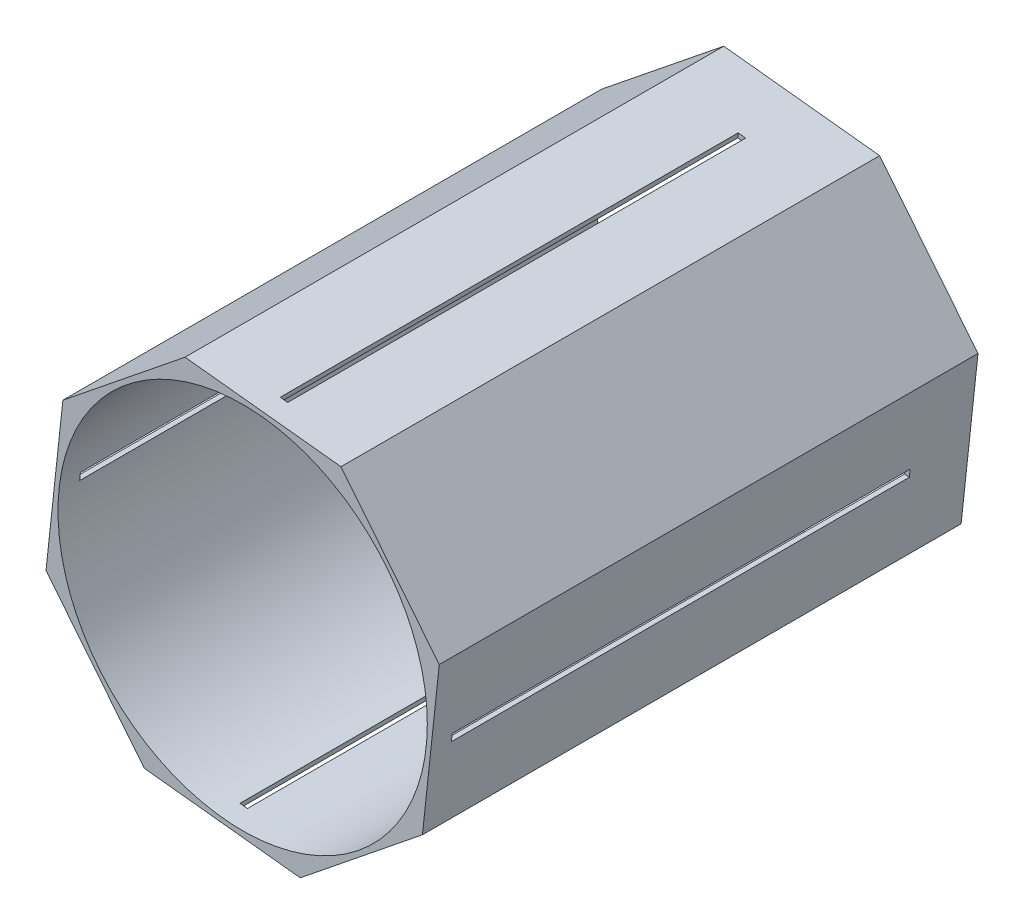
from build123d import *

# Parameters (mm, degrees)
SKETCH1_R           = 78.359
BOSS_EXTRUDE1_DEPTH = 228.6
SKETCH2_W           = 3.175
SKETCH2_H           = 194.31
CUT_EXTRUDE1_DEPTH  = 203.2
SKETCH5_W           = 194.31
SKETCH5_H           = 3.175
CUT_EXTRUDE2_DEPTH  = 203.2


with BuildPart() as part:
    # Sketch1 → Boss-Extrude1 (new body)
    with BuildSketch(Plane.XY):
        Polygon((76.286003624, -41.721564111), (83.443951376, 24.440749568), (41.721564111, 76.286003624), (-24.440749568, 83.443951376), (-76.286003624, 41.721564111), (-83.443951376, -24.440749568), (-41.721564111, -76.286003624), (24.440749568, -83.443951376), align=None)
        Circle(SKETCH1_R, mode=Mode.SUBTRACT)
    extrude(amount=BOSS_EXTRUDE1_DEPTH)

    # Sketch2 → Cut-Extrude1 (cut)
    with BuildSketch(Plane(origin=(8.640407271, 79.8649775, 0), x_dir=(0.99419859, -0.107560047, 0), z_dir=(0.107560047, 0.99419859, 0))):
        with Locations((0, -122.555)):
            Rectangle(SKETCH2_W, SKETCH2_H)
    extrude(amount=-CUT_EXTRUDE1_DEPTH, mode=Mode.SUBTRACT)

    # Sketch5 → Cut-Extrude2 (cut)
    with BuildSketch(Plane(origin=(-79.8649775, 8.640407271, 0), x_dir=(0, 0, 1), z_dir=(-0.99419859, 0.107560047, 0))):
        with Locations((122.555, 0)):
            Rectangle(SKETCH5_W, SKETCH5_H)
    extrude(amount=-CUT_EXTRUDE2_DEPTH, mode=Mode.SUBTRACT)


solid = part.part
